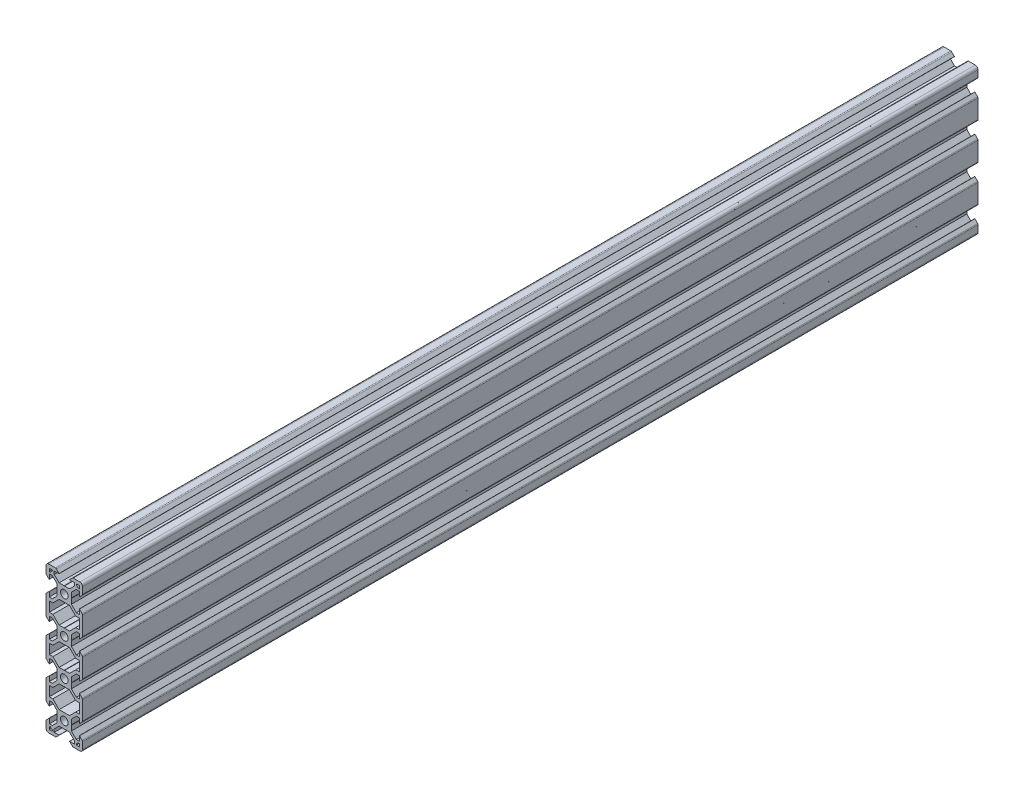
from build123d import *

# Parameters (mm, degrees)
SKETCH3_R           = 2.1
BOSS_EXTRUDE1_DEPTH = 244.75


with BuildPart() as part:
    # Sketch3 → Boss-Extrude1 (new body, symmetric)
    with BuildSketch(Plane.XY):
        with BuildLine():
            Line((-0.1, 3.9), (0, 3.8))
            Line((0, 3.8), (0.1, 3.9))
            Line((0.1, 3.9), (2.840365134, 3.9))
            Line((2.840365134, 3.9), (5.5, 6.558825842))
            Line((5.5, 6.558825842), (5.5, 8.197505675))
            Line((5.5, 8.197505675), (2.89, 8.197505675))
            Line((2.89, 8.197505675), (2.89, 8.307505675))
            Line((2.89, 8.307505675), (4.348614357, 9.766120032))
            ThreePointArc((4.348614357, 9.766120032), (4.604908803, 9.937370505), (4.907228714, 9.997505675))
            Line((4.907228714, 9.997505675), (8.5, 9.997505675))
            ThreePointArc((8.5, 9.997505675), (9.560660172, 9.558165846), (10, 8.497505675))
            Line((10, 8.497505675), (10, 4.904734389))
            ThreePointArc((10, 4.904734389), (9.939864831, 4.602414477), (9.768614357, 4.346120032))
            Line((9.768614357, 4.346120032), (8.31, 2.887505675))
            Line((8.31, 2.887505675), (8.2, 2.887505675))
            Line((8.2, 2.887505675), (8.2, 5.497505675))
            Line((8.2, 5.497505675), (6.56, 5.497505675))
            Line((6.56, 5.497505675), (3.9, 2.83831481))
            Line((3.9, 2.83831481), (3.9, 0.1))
            Line((3.9, 0.1), (3.8, 0))
            Line((3.8, 0), (3.9, -0.1))
            Line((3.9, -0.1), (3.9, -2.84))
            Line((3.9, -2.84), (6.56, -5.5))
            Line((6.56, -5.5), (8.21, -5.5))
            Line((8.21, -5.5), (8.21, -2.89))
            Line((8.21, -2.89), (8.31, -2.89))
            Line((8.31, -2.89), (9.765685425, -4.345685425))
            ThreePointArc((9.765685425, -4.345685425), (9.939103626, -4.605224104), (10, -4.91137085))
            Line((10, -4.91137085), (10, -15.08862915))
            ThreePointArc((10, -15.08862915), (9.939103626, -15.394775896), (9.765685425, -15.654314575))
            Line((9.765685425, -15.654314575), (8.31, -17.11))
            Line((8.31, -17.11), (8.21, -17.11))
            Line((8.21, -17.11), (8.21, -14.5))
            Line((8.21, -14.5), (6.56, -14.5))
            Line((6.56, -14.5), (3.9, -17.16))
            Line((3.9, -17.16), (3.9, -19.9))
            Line((3.9, -19.9), (3.8, -20))
            Line((3.8, -20), (3.9, -20.1))
            Line((3.9, -20.1), (3.9, -22.838679656))
            Line((3.9, -22.838679656), (6.56, -25.498679656))
            Line((6.56, -25.498679656), (8.21, -25.498679656))
            Line((8.21, -25.498679656), (8.21, -22.888679656))
            Line((8.21, -22.888679656), (8.31, -22.888679656))
            Line((8.31, -22.888679656), (9.765685425, -24.344365081))
            ThreePointArc((9.765685425, -24.344365081), (9.939103626, -24.60390376), (10, -24.910050506))
            Line((10, -24.910050506), (10, -35.109949494))
            ThreePointArc((10, -35.109949494), (9.939103626, -35.41609624), (9.765685425, -35.675634919))
            Line((9.765685425, -35.675634919), (8.31, -37.131320344))
            Line((8.31, -37.131320344), (8.21, -37.131320344))
            Line((8.21, -37.131320344), (8.21, -34.521320344))
            Line((8.21, -34.521320344), (6.56, -34.521320344))
            Line((6.56, -34.521320344), (3.9, -37.181320344))
            Line((3.9, -37.181320344), (3.9, -39.92))
            Line((3.9, -39.92), (3.8, -40.02))
            Line((3.8, -40.02), (3.9, -40.12))
            Line((3.9, -40.12), (3.9, -42.86))
            Line((3.9, -42.86), (6.56, -45.52))
            Line((6.56, -45.52), (8.21, -45.52))
            Line((8.21, -45.52), (8.21, -42.91))
            Line((8.21, -42.91), (8.31, -42.91))
            Line((8.31, -42.91), (9.765685425, -44.365685425))
            ThreePointArc((9.765685425, -44.365685425), (9.939103626, -44.625224104), (10, -44.93137085))
            Line((10, -44.93137085), (10, -55.10862915))
            ThreePointArc((10, -55.10862915), (9.939103626, -55.414775896), (9.765685425, -55.674314575))
            Line((9.765685425, -55.674314575), (8.31, -57.13))
            Line((8.31, -57.13), (8.21, -57.13))
            Line((8.21, -57.13), (8.21, -54.52))
            Line((8.21, -54.52), (6.56, -54.52))
            Line((6.56, -54.52), (3.9, -57.18))
            Line((3.9, -57.18), (3.9, -59.92))
            Line((3.9, -59.92), (3.8, -60.02))
            Line((3.8, -60.02), (3.9, -60.12))
            Line((3.9, -60.12), (3.9, -62.85831481))
            Line((3.9, -62.85831481), (6.56, -65.517505675))
            Line((6.56, -65.517505675), (8.2, -65.517505675))
            Line((8.2, -65.517505675), (8.2, -62.907505675))
            Line((8.2, -62.907505675), (8.31, -62.907505675))
            Line((8.31, -62.907505675), (9.768614357, -64.366120032))
            ThreePointArc((9.768614357, -64.366120032), (9.939864831, -64.622414477), (10, -64.924734389))
            Line((10, -64.924734389), (10, -68.517505675))
            ThreePointArc((10, -68.517505675), (9.560660172, -69.578165846), (8.5, -70.017505675))
            Line((8.5, -70.017505675), (4.907228714, -70.017505675))
            ThreePointArc((4.907228714, -70.017505675), (4.604908803, -69.957370505), (4.348614357, -69.786120032))
            Line((4.348614357, -69.786120032), (2.89, -68.327505675))
            Line((2.89, -68.327505675), (2.89, -68.217505675))
            Line((2.89, -68.217505675), (5.5, -68.217505675))
            Line((5.5, -68.217505675), (5.5, -66.578825842))
            Line((5.5, -66.578825842), (2.840365134, -63.92))
            Line((2.840365134, -63.92), (0.1, -63.92))
            Line((0.1, -63.92), (0, -63.82))
            Line((0, -63.82), (-0.1, -63.92))
            Line((-0.1, -63.92), (-2.840365134, -63.92))
            Line((-2.840365134, -63.92), (-5.5, -66.578825842))
            Line((-5.5, -66.578825842), (-5.5, -68.217505675))
            Line((-5.5, -68.217505675), (-2.89, -68.217505675))
            Line((-2.89, -68.217505675), (-2.89, -68.327505675))
            Line((-2.89, -68.327505675), (-4.348614357, -69.786120032))
            ThreePointArc((-4.348614357, -69.786120032), (-4.604908803, -69.957370505), (-4.907228714, -70.017505675))
            Line((-4.907228714, -70.017505675), (-8.5, -70.017505675))
            ThreePointArc((-8.5, -70.017505675), (-9.560660172, -69.578165846), (-10, -68.517505675))
            Line((-10, -68.517505675), (-10, -64.924734389))
            ThreePointArc((-10, -64.924734389), (-9.939864831, -64.622414477), (-9.768614357, -64.366120032))
            Line((-9.768614357, -64.366120032), (-8.31, -62.907505675))
            Line((-8.31, -62.907505675), (-8.2, -62.907505675))
            Line((-8.2, -62.907505675), (-8.2, -65.517505675))
            Line((-8.2, -65.517505675), (-6.56, -65.517505675))
            Line((-6.56, -65.517505675), (-3.9, -62.85831481))
            Line((-3.9, -62.85831481), (-3.9, -60.12))
            Line((-3.9, -60.12), (-3.8, -60.02))
            Line((-3.8, -60.02), (-3.9, -59.92))
            Line((-3.9, -59.92), (-3.9, -57.18))
            Line((-3.9, -57.18), (-6.56, -54.52))
            Line((-6.56, -54.52), (-8.21, -54.52))
            Line((-8.21, -54.52), (-8.21, -57.13))
            Line((-8.21, -57.13), (-8.31, -57.13))
            Line((-8.31, -57.13), (-9.765685425, -55.674314575))
            ThreePointArc((-9.765685425, -55.674314575), (-9.939103626, -55.414775896), (-10, -55.10862915))
            Line((-10, -55.10862915), (-10, -44.93137085))
            ThreePointArc((-10, -44.93137085), (-9.939103626, -44.625224104), (-9.765685425, -44.365685425))
            Line((-9.765685425, -44.365685425), (-8.31, -42.91))
            Line((-8.31, -42.91), (-8.21, -42.91))
            Line((-8.21, -42.91), (-8.21, -45.52))
            Line((-8.21, -45.52), (-6.56, -45.52))
            Line((-6.56, -45.52), (-3.9, -42.86))
            Line((-3.9, -42.86), (-3.9, -40.12))
            Line((-3.9, -40.12), (-3.8, -40.02))
            Line((-3.8, -40.02), (-3.9, -39.92))
            Line((-3.9, -39.92), (-3.9, -37.181320344))
            Line((-3.9, -37.181320344), (-6.56, -34.521320344))
            Line((-6.56, -34.521320344), (-8.21, -34.521320344))
            Line((-8.21, -34.521320344), (-8.21, -37.131320344))
            Line((-8.21, -37.131320344), (-8.31, -37.131320344))
            Line((-8.31, -37.131320344), (-9.765685425, -35.675634919))
            ThreePointArc((-9.765685425, -35.675634919), (-9.939103626, -35.41609624), (-10, -35.109949494))
            Line((-10, -35.109949494), (-10, -24.910050506))
            ThreePointArc((-10, -24.910050506), (-9.939103626, -24.60390376), (-9.765685425, -24.344365081))
            Line((-9.765685425, -24.344365081), (-8.31, -22.888679656))
            Line((-8.31, -22.888679656), (-8.21, -22.888679656))
            Line((-8.21, -22.888679656), (-8.21, -25.498679656))
            Line((-8.21, -25.498679656), (-6.56, -25.498679656))
            Line((-6.56, -25.498679656), (-3.9, -22.838679656))
            Line((-3.9, -22.838679656), (-3.9, -20.1))
            Line((-3.9, -20.1), (-3.8, -20))
            Line((-3.8, -20), (-3.9, -19.9))
            Line((-3.9, -19.9), (-3.9, -17.16))
            Line((-3.9, -17.16), (-6.56, -14.5))
            Line((-6.56, -14.5), (-8.21, -14.5))
            Line((-8.21, -14.5), (-8.21, -17.11))
            Line((-8.21, -17.11), (-8.31, -17.11))
            Line((-8.31, -17.11), (-9.765685425, -15.654314575))
            ThreePointArc((-9.765685425, -15.654314575), (-9.939103626, -15.394775896), (-10, -15.08862915))
            Line((-10, -15.08862915), (-10, -4.91137085))
            ThreePointArc((-10, -4.91137085), (-9.939103626, -4.605224104), (-9.765685425, -4.345685425))
            Line((-9.765685425, -4.345685425), (-8.31, -2.89))
            Line((-8.31, -2.89), (-8.21, -2.89))
            Line((-8.21, -2.89), (-8.21, -5.5))
            Line((-8.21, -5.5), (-6.56, -5.5))
            Line((-6.56, -5.5), (-3.9, -2.84))
            Line((-3.9, -2.84), (-3.9, -0.1))
            Line((-3.9, -0.1), (-3.8, 0))
            Line((-3.8, 0), (-3.9, 0.1))
            Line((-3.9, 0.1), (-3.9, 2.83831481))
            Line((-3.9, 2.83831481), (-6.56, 5.497505675))
            Line((-6.56, 5.497505675), (-8.2, 5.497505675))
            Line((-8.2, 5.497505675), (-8.2, 2.887505675))
            Line((-8.2, 2.887505675), (-8.31, 2.887505675))
            Line((-8.31, 2.887505675), (-9.768614357, 4.346120032))
            ThreePointArc((-9.768614357, 4.346120032), (-9.939864831, 4.602414477), (-10, 4.904734389))
            Line((-10, 4.904734389), (-10, 8.497505675))
            ThreePointArc((-10, 8.497505675), (-9.560660172, 9.558165846), (-8.5, 9.997505675))
            Line((-8.5, 9.997505675), (-4.907228714, 9.997505675))
            ThreePointArc((-4.907228714, 9.997505675), (-4.604908803, 9.937370505), (-4.348614357, 9.766120032))
            Line((-4.348614357, 9.766120032), (-2.89, 8.307505675))
            Line((-2.89, 8.307505675), (-2.89, 8.197505675))
            Line((-2.89, 8.197505675), (-5.5, 8.197505675))
            Line((-5.5, 8.197505675), (-5.5, 6.558825842))
            Line((-5.5, 6.558825842), (-2.840365134, 3.9))
            Line((-2.840365134, 3.9), (-0.1, 3.9))
        make_face()
        Circle(SKETCH3_R, mode=Mode.SUBTRACT)
        with Locations((0, -20)):
            Circle(SKETCH3_R, mode=Mode.SUBTRACT)
        with Locations((0, -40.02)):
            Circle(SKETCH3_R, mode=Mode.SUBTRACT)
        with Locations((0, -60.02)):
            Circle(SKETCH3_R, mode=Mode.SUBTRACT)
        Polygon((-7.66, 6.567505675), (-6.57, 7.657505675), (-6.57, 8.197505675), (-8.2, 8.197505675), (-8.2, 6.567505675), align=None, mode=Mode.SUBTRACT)
        Polygon((2.840365134, -3.9), (-2.840365134, -3.9), (-6.25, -7.309634866), (-8.21, -7.309634866), (-8.21, -12.7), (-6.25, -12.7), (-2.85, -16.1), (-0.1, -16.1), (0, -16.2), (0.1, -16.1), (2.85, -16.1), (6.25, -12.7), (8.21, -12.7), (8.21, -7.309634866), (6.25, -7.309634866), align=None, mode=Mode.SUBTRACT)
        Polygon((-0.1, -23.9), (0, -23.8), (0.1, -23.9), (2.84, -23.9), (6.25, -27.31), (8.21, -27.31), (8.21, -32.71), (6.25, -32.71), (2.84, -36.12), (0.1, -36.12), (0, -36.22), (-0.1, -36.12), (-2.84, -36.12), (-6.25, -32.71), (-8.21, -32.71), (-8.21, -27.31), (-6.25, -27.31), (-2.84, -23.9), align=None, mode=Mode.SUBTRACT)
        Polygon((8.2, 6.567505675), (7.66, 6.567505675), (6.57, 7.657505675), (6.57, 8.197505675), (8.2, 8.197505675), align=None, mode=Mode.SUBTRACT)
        Polygon((7.66, -66.587505675), (6.57, -67.677505675), (6.57, -68.217505675), (8.2, -68.217505675), (8.2, -66.587505675), align=None, mode=Mode.SUBTRACT)
        Polygon((2.840365134, -56.12), (6.25, -52.710365134), (8.21, -52.710365134), (8.21, -47.32), (6.25, -47.32), (2.85, -43.92), (0.1, -43.92), (0, -43.82), (-0.1, -43.92), (-2.85, -43.92), (-6.25, -47.32), (-8.21, -47.32), (-8.21, -52.710365134), (-6.25, -52.710365134), (-2.840365134, -56.12), align=None, mode=Mode.SUBTRACT)
        Polygon((-8.2, -66.587505675), (-7.66, -66.587505675), (-6.57, -67.677505675), (-6.57, -68.217505675), (-8.2, -68.217505675), align=None, mode=Mode.SUBTRACT)
    extrude(amount=BOSS_EXTRUDE1_DEPTH, both=True)


solid = part.part
